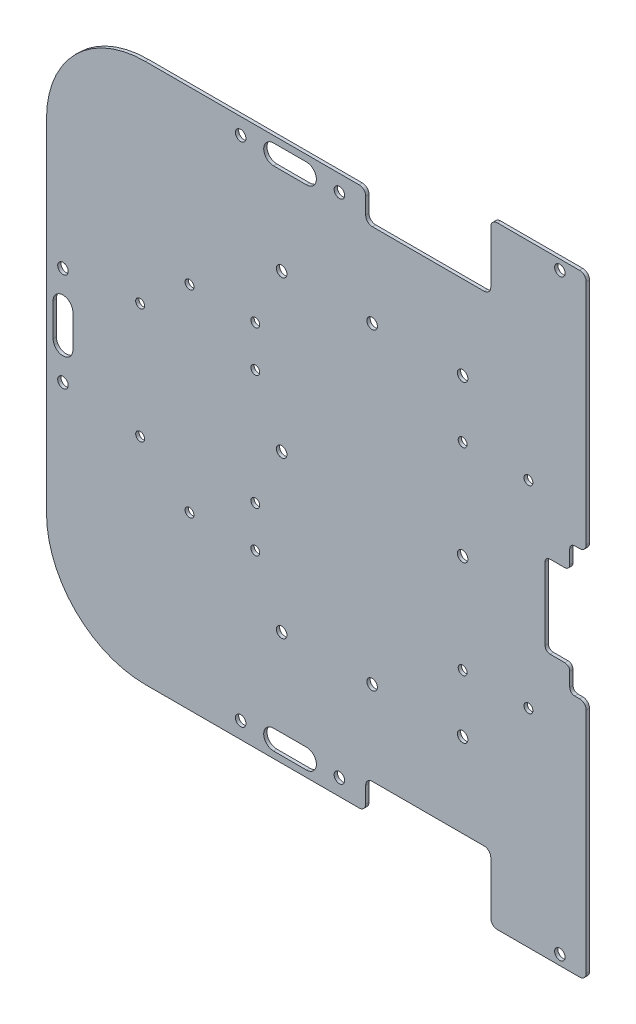
from build123d import *

# Parameters (mm, degrees)
SKETCH_1_W          = 164
SKETCH_1_H          = 164
EXTRUDE_1_DEPTH     = 1
FILLET_1_R          = 30
SKETCH_2_R          = 1.6
CUT_EXTRUDE_1_DEPTH = 2
SKETCH_3_R          = 1.6
CUT_EXTRUDE_2_DEPTH = 2
SKETCH_4_W          = 38
SKETCH_4_H          = 9
CUT_EXTRUDE_3_DEPTH = 2
SKETCH_5_W          = 1
SKETCH_5_H          = 9.5
CUT_EXTRUDE_4_DEPTH = 5
FILLET_3_R          = 1.5
SKETCH_6_W          = 29
SKETCH_6_H          = 11
EXTRUDE_2_DEPTH     = 1
FILLET_2_R          = 2
SKETCH_8_R          = 1.6
CUT_EXTRUDE_5_DEPTH = 2
SKETCH_10_R         = 1.599999996
SKETCH_10_R_2       = 1.600000004
SKETCH_10_R_3       = 1.35
CUT_EXTRUDE_6_DEPTH = 2
CUT_EXTRUDE_7_DEPTH = 2
FILLET_4_R          = 1.5


with BuildPart() as part:
    # 草图1 → 凸台-拉伸1 (new body)
    with BuildSketch(Plane.XY):
        with Locations((82, 82)):
            Rectangle(SKETCH_1_W, SKETCH_1_H)
    extrude(amount=EXTRUDE_1_DEPTH)

    # 圆角1
    fillet_1_edges = [part.edges().sort_by_distance(p)[0] for p in [
        (0, 164, 0.5),
        (0, 0, 0.5),
    ]]
    fillet(fillet_1_edges, radius=FILLET_1_R)

    # 草图2 → 切除-拉伸1 (cut, through all)
    with BuildSketch(Plane.XY.offset(1)):
        with Locations((5, 97)):
            Circle(SKETCH_2_R)
        with Locations((5, 67)):
            Circle(SKETCH_2_R)
        with BuildLine():
            Line((2, 77), (2, 87))
            ThreePointArc((2, 87), (5, 90), (8, 87))
            Line((8, 87), (8, 77))
            ThreePointArc((8, 77), (5, 74), (2, 77))
        make_face()
    extrude(amount=-CUT_EXTRUDE_1_DEPTH, mode=Mode.SUBTRACT)

    # 草图3 → 切除-拉伸2 (cut, through all)
    with BuildSketch(Plane.XY.offset(1)):
        with Locations((59, 5)):
            Circle(SKETCH_3_R)
        with Locations((89, 5)):
            Circle(SKETCH_3_R)
        with Locations((89, 159)):
            Circle(SKETCH_3_R)
        with Locations((59, 159)):
            Circle(SKETCH_3_R)
        with BuildLine():
            Line((79, 2), (69, 2))
            ThreePointArc((69, 2), (66, 5), (69, 8))
            Line((69, 8), (79, 8))
            ThreePointArc((79, 8), (82, 5), (79, 2))
        make_face()
        with BuildLine():
            Line((79, 162), (69, 162))
            ThreePointArc((69, 162), (66, 159), (69, 156))
            Line((69, 156), (79, 156))
            ThreePointArc((79, 156), (82, 159), (79, 162))
        make_face()
    extrude(amount=-CUT_EXTRUDE_2_DEPTH, mode=Mode.SUBTRACT)

    # 草图4 → 切除-拉伸3 (cut, through all)
    with BuildSketch(Plane.XY.offset(1)):
        with Locations((116, 159.5)):
            Rectangle(SKETCH_4_W, SKETCH_4_H)
        with Locations((116, 4.5)):
            Rectangle(SKETCH_4_W, SKETCH_4_H)
    extrude(amount=-CUT_EXTRUDE_3_DEPTH, mode=Mode.SUBTRACT)

    # 草图5 → 切除-拉伸4 (cut)
    with BuildSketch(Plane(origin=(164, 0, 0), x_dir=(0, 0, -1), z_dir=(1, 0, 0))):
        with Locations((-0.5, 67)):
            Rectangle(SKETCH_5_W, SKETCH_5_H)
        with Locations((-0.5, 97)):
            Rectangle(SKETCH_5_W, SKETCH_5_H)
    extrude(amount=-CUT_EXTRUDE_4_DEPTH, mode=Mode.SUBTRACT)

    # 圆角3
    fillet_3_edges = [part.edges().sort_by_distance(p)[0] for p in [
        (159, 62.25, 0.5),
        (159, 71.75, 0.5),
        (159, 101.75, 0.5),
        (159, 92.25, 0.5),
    ]]
    fillet(fillet_3_edges, radius=FILLET_3_R)

    # 草图6 → 凸台-拉伸2 (add)
    with BuildSketch(Plane.XY.offset(1)):
        with Locations((149.5, 169.5)):
            Rectangle(SKETCH_6_W, SKETCH_6_H)
        with Locations((149.5, -5.5)):
            Rectangle(SKETCH_6_W, SKETCH_6_H)
    extrude(amount=-EXTRUDE_2_DEPTH)

    # 圆角2
    fillet_2_edges = [part.edges().sort_by_distance(p)[0] for p in [
        (135, 155, 0.5),
        (97, 155, 0.5),
        (97, 164, 0.5),
        (97, 0, 0.5),
        (97, 9, 0.5),
        (135, 9, 0.5),
        (164, 71.75, 0.5),
        (164, 62.25, 0.5),
        (164, 92.25, 0.5),
        (164, 101.75, 0.5),
        (164, 175, 0.5),
        (135, 175, 0.5),
        (164, -11, 0.5),
        (135, -11, 0.5),
    ]]
    fillet(fillet_2_edges, radius=FILLET_2_R)

    # 草图8 → 切除-拉伸5 (cut, through all)
    with BuildSketch(Plane.XY.offset(1)):
        with Locations((156, 172)):
            Circle(SKETCH_8_R)
        with Locations((156, -8)):
            Circle(SKETCH_8_R)
    extrude(amount=-CUT_EXTRUDE_5_DEPTH, mode=Mode.SUBTRACT)

    # 草图10 → 切除-拉伸6 (cut, through all)
    with BuildSketch(Plane.XY.offset(1)):
        with Locations((71.449193661, 129.5)):
            Circle(SKETCH_10_R)
        with Locations((98.949193661, 129.5)):
            Circle(SKETCH_10_R)
        with Locations((126.449193661, 129.5)):
            Circle(SKETCH_10_R)
        with Locations((71.449193661, 82)):
            Circle(SKETCH_10_R)
        with Locations((126.449193661, 34.5)):
            Circle(SKETCH_10_R)
        with Locations((98.949193661, 34.5)):
            Circle(SKETCH_10_R)
        with Locations((71.449193661, 34.5)):
            Circle(SKETCH_10_R)
        with Locations((126.449193661, 82)):
            Circle(SKETCH_10_R_2)
        with Locations((28.449193661, 99.5)):
            Circle(SKETCH_10_R_3)
        with Locations((63.449193661, 99.5)):
            Circle(SKETCH_10_R_3)
        with Locations((63.449193661, 64.5)):
            Circle(SKETCH_10_R_3)
        with Locations((28.449193661, 64.5)):
            Circle(SKETCH_10_R_3)
        with Locations((146.449193661, 112)):
            Circle(SKETCH_10_R_3)
        with Locations((43.449193661, 112)):
            Circle(SKETCH_10_R_3)
        with Locations((63.449193661, 112)):
            Circle(SKETCH_10_R_3)
        with Locations((63.449193661, 52)):
            Circle(SKETCH_10_R_3)
        with Locations((43.449193661, 52)):
            Circle(SKETCH_10_R_3)
        with Locations((126.449193661, 112)):
            Circle(SKETCH_10_R_3)
        with Locations((146.449193661, 52)):
            Circle(SKETCH_10_R_3)
        with Locations((126.449193661, 52)):
            Circle(SKETCH_10_R_3)
    extrude(amount=-CUT_EXTRUDE_6_DEPTH, mode=Mode.SUBTRACT)

    # 草图12 → 切除-拉伸7 (cut, through all)
    with BuildSketch(Plane.XY.offset(1)):
        with BuildLine():
            Line((159, 94.5), (151.5, 94.5))
            Line((151.5, 94.5), (151.5, 69.5))
            Line((151.5, 69.5), (159, 69.5))
            Line((159, 69.5), (159, 70.25))
            ThreePointArc((159, 70.25), (159.439339828, 71.310660172), (160.5, 71.75))
            Line((160.5, 71.75), (162, 71.75))
            ThreePointArc((162, 71.75), (163.414213562, 72.335786438), (164, 73.75))
            Line((164, 73.75), (164, 90.25))
            ThreePointArc((164, 90.25), (163.414213562, 91.664213562), (162, 92.25))
            Line((162, 92.25), (160.5, 92.25))
            ThreePointArc((160.5, 92.25), (159.439339828, 92.689339828), (159, 93.75))
            Line((159, 93.75), (159, 94.5))
        make_face()
    extrude(amount=-CUT_EXTRUDE_7_DEPTH, mode=Mode.SUBTRACT)

    # 圆角4
    fillet_4_edges = [part.edges().sort_by_distance(p)[0] for p in [
        (159, 94.5, 0.5),
        (159, 69.5, 0.5),
        (151.5, 69.5, 0.5),
        (151.5, 94.5, 0.5),
    ]]
    fillet(fillet_4_edges, radius=FILLET_4_R)


solid = part.part
